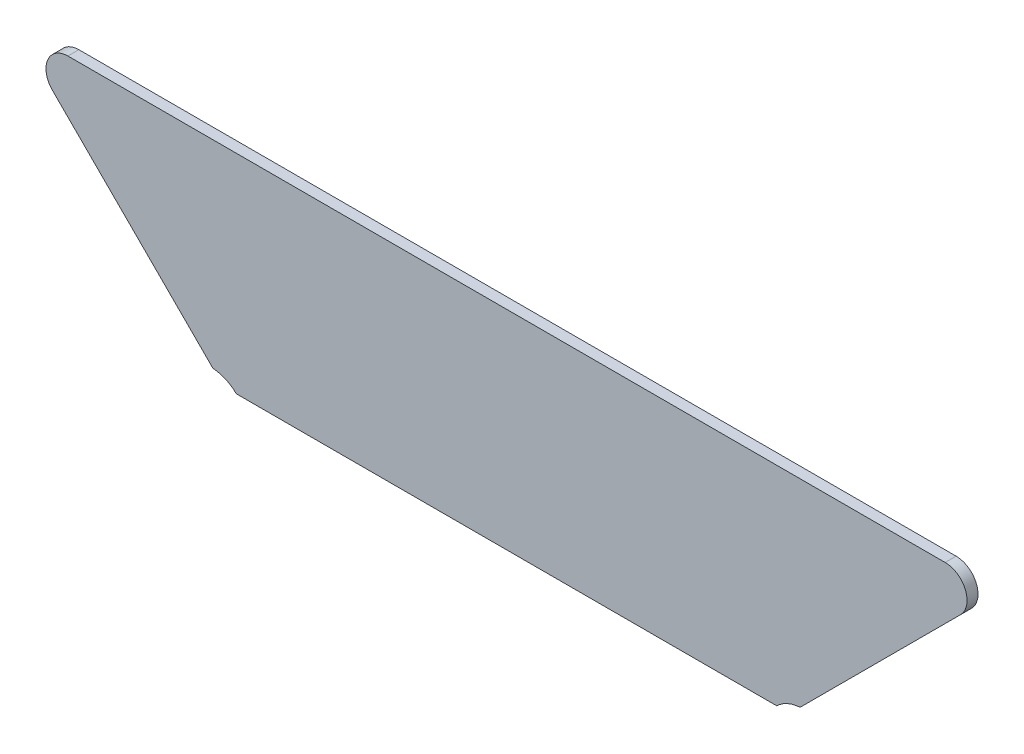
from build123d import *

# Parameters (mm, degrees)
BOSS_EXTRUDE1_DEPTH = 1


with BuildPart() as part:
    # Sketch1 → Boss-Extrude1 (new body)
    with BuildSketch(Plane.XY):
        with BuildLine():
            Line((-10, 99), (-90, 99))
            ThreePointArc((-90, 99), (-91.847759065, 97.765366865), (-91.414213562, 95.585786438))
            Line((-91.414213562, 95.585786438), (-76.779190676, 80.950763551))
            ThreePointArc((-76.779190676, 80.950763551), (-75.624966785, 80.666127277), (-74.640322152, 80))
            Line((-74.640322152, 80), (-25.359677848, 80))
            ThreePointArc((-25.359677848, 80), (-24.375033215, 80.666127277), (-23.220809324, 80.950763551))
            Line((-23.220809324, 80.950763551), (-8.585786438, 95.585786438))
            ThreePointArc((-8.585786438, 95.585786438), (-8.152240935, 97.765366865), (-10, 99))
        make_face()
    extrude(amount=BOSS_EXTRUDE1_DEPTH)


solid = part.part
